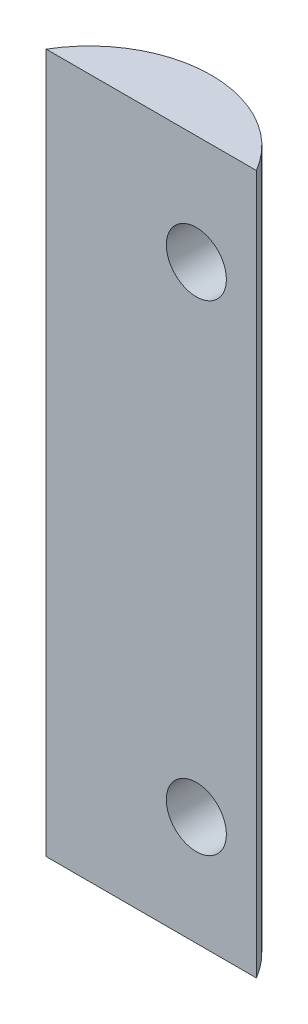
from build123d import *

# Parameters (mm, degrees)
BOSS_EXTRUDE1_START     = -6.35
BOSS_EXTRUDE1_DEPTH     = 73.930002
SKETCH1_R               = 3.175
CUT_EXTRUDE2_DEPTH      = 1
CUT_EXTRUDE2_DEPTH_BACK = 7.35


with BuildPart() as part:
    # Sketch2 → Boss-Extrude1 (new body)
    with BuildSketch(Plane(origin=(0, 0, 0), x_dir=(1, 0, 0), z_dir=(0, 1, 0)).offset(BOSS_EXTRUDE1_START)):
        with BuildLine():
            Line((0, 0), (6.35, 0))
            ThreePointArc((6.35, 0), (-4.7625, 6.35), (-15.875, 0))
            Line((-15.875, 0), (0, 0))
        make_face()
    extrude(amount=BOSS_EXTRUDE1_DEPTH)

    # Sketch1 → Cut-Extrude2 (cut, two sides)
    with BuildSketch(Plane.XY) as cut_extrude2_sk:
        with Locations((0, 56.015128)):
            Circle(SKETCH1_R)
        with Locations((0, 5.214874)):
            Circle(SKETCH1_R)
    extrude(amount=CUT_EXTRUDE2_DEPTH, mode=Mode.SUBTRACT)
    extrude(cut_extrude2_sk.sketch, amount=-CUT_EXTRUDE2_DEPTH_BACK, mode=Mode.SUBTRACT)


solid = part.part
